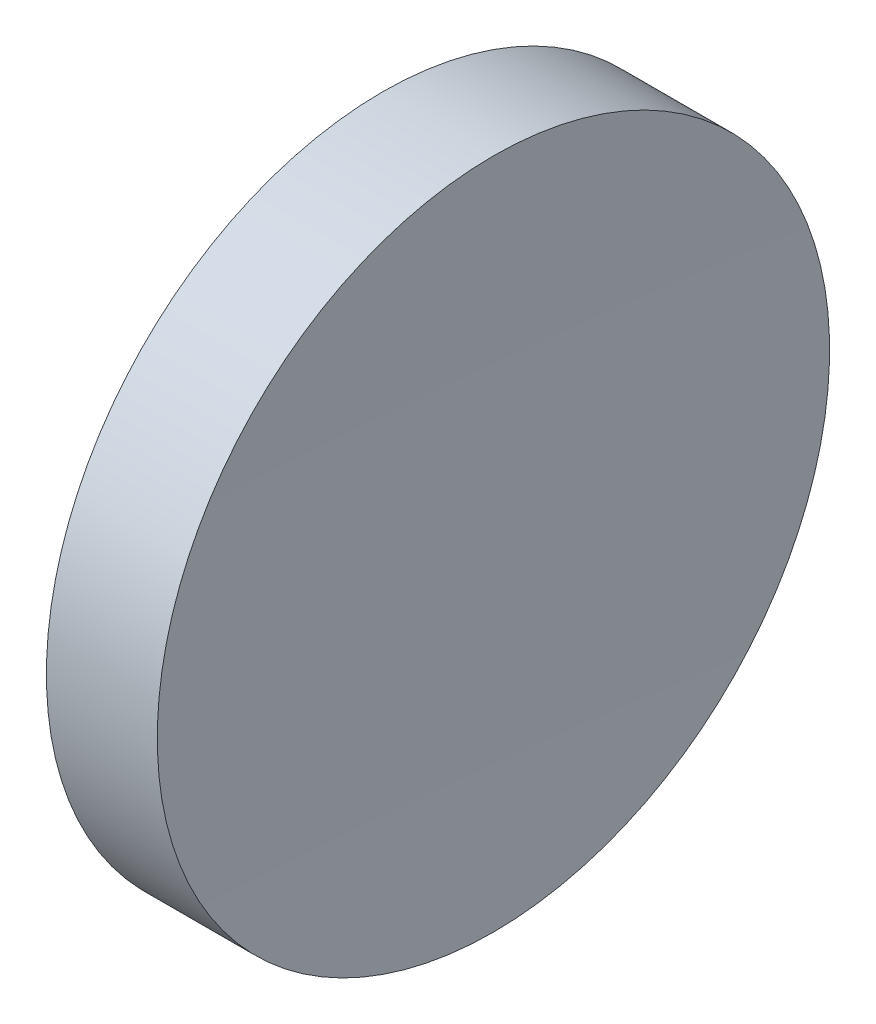
from build123d import *


with BuildPart() as part:
    # 草图1 → 旋转1 (revolve)
    with BuildSketch(Plane.XY):
        with BuildLine():
            Line((61.493634096, 38.858420235), (63.555304632, 38.858420235))
            ThreePointArc((63.555304632, 38.858420235), (63.494259987, 35.733685224), (63.473910621, 32.608420235))
            Line((63.473910621, 32.608420235), (61.273910621, 32.608420235))
            ThreePointArc((61.273910621, 32.608420235), (61.328858452, 35.735350775), (61.493634096, 38.858420235))
        make_face()
    revolve(axis=Axis((57.972245649, 32.608420235, 0), (1, 0, 0)))


solid = part.part
